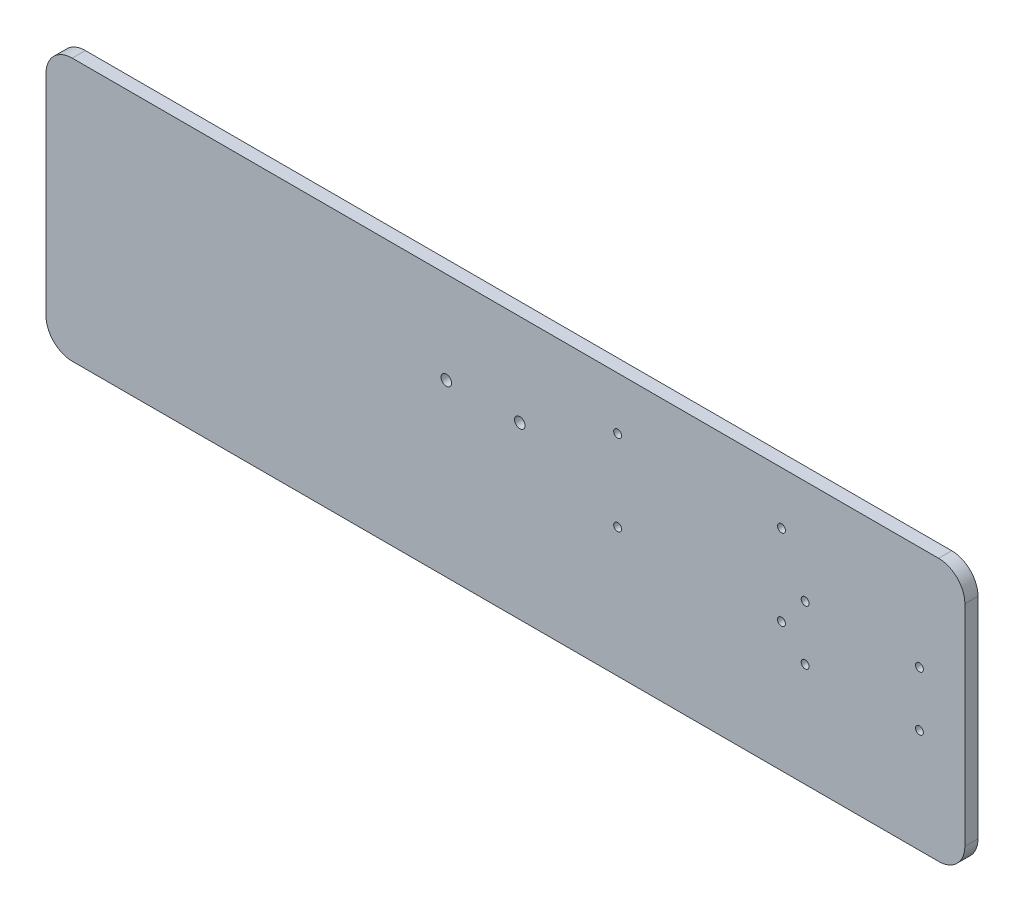
from build123d import *

# Parameters (mm, degrees)
BOSS_EXTRUDE1_DEPTH = 5
CUT_EXTRUDE1_REACH  = 7
SKETCH2_R           = 2
SKETCH2_R_2         = 1.5


with BuildPart() as part:
    # Sketch1 → Boss-Extrude1 (new body)
    with BuildSketch(Plane.XY):
        with BuildLine():
            Line((-165, -50), (165, -50))
            ThreePointArc((165, -50), (172.071067812, -47.071067812), (175, -40))
            Line((175, -40), (175, 40))
            ThreePointArc((175, 40), (172.071067812, 47.071067812), (165, 50))
            Line((165, 50), (-165, 50))
            ThreePointArc((-165, 50), (-172.071067812, 47.071067812), (-175, 40))
            Line((-175, 40), (-175, -40))
            ThreePointArc((-175, -40), (-172.071067812, -47.071067812), (-165, -50))
        make_face()
    extrude(amount=BOSS_EXTRUDE1_DEPTH)

    # Sketch2 → Cut-Extrude1 (cut, up to next)
    with BuildSketch(Plane(origin=(0, 0, 0), x_dir=(-1, 0, 0), z_dir=(0, 0, -1)), mode=Mode.PRIVATE) as cut_extrude1_sk1:
        with Locations((-5.457089812, 15)):
            Circle(SKETCH2_R)
    cut_extrude1_tool1 = extrude(cut_extrude1_sk1.sketch, amount=-CUT_EXTRUDE1_REACH, mode=Mode.PRIVATE) & part.part
    add(cut_extrude1_tool1.solids().sort_by_distance((5.45709, 15, 0))[0], mode=Mode.SUBTRACT)
    # Sketch2 → Cut-Extrude1 (cut, up to next)
    with BuildSketch(Plane(origin=(0, 0, 0), x_dir=(-1, 0, 0), z_dir=(0, 0, -1)), mode=Mode.PRIVATE) as cut_extrude1_sk2:
        with Locations((22.528132313, 15)):
            Circle(SKETCH2_R)
    cut_extrude1_tool2 = extrude(cut_extrude1_sk2.sketch, amount=-CUT_EXTRUDE1_REACH, mode=Mode.PRIVATE) & part.part
    add(cut_extrude1_tool2.solids().sort_by_distance((-22.528132, 15, 0))[0], mode=Mode.SUBTRACT)
    # Sketch2 → Cut-Extrude1 (cut, up to next)
    with BuildSketch(Plane(origin=(0, 0, 0), x_dir=(-1, 0, 0), z_dir=(0, 0, -1)), mode=Mode.PRIVATE) as cut_extrude1_sk3:
        with Locations((-105.153812798, 30)):
            Circle(SKETCH2_R_2)
    cut_extrude1_tool3 = extrude(cut_extrude1_sk3.sketch, amount=-CUT_EXTRUDE1_REACH, mode=Mode.PRIVATE) & part.part
    add(cut_extrude1_tool3.solids().sort_by_distance((105.153813, 30, 0))[0], mode=Mode.SUBTRACT)
    # Sketch2 → Cut-Extrude1 (cut, up to next)
    with BuildSketch(Plane(origin=(0, 0, 0), x_dir=(-1, 0, 0), z_dir=(0, 0, -1)), mode=Mode.PRIVATE) as cut_extrude1_sk4:
        with Locations((-42.738382893, 30)):
            Circle(SKETCH2_R_2)
    cut_extrude1_tool4 = extrude(cut_extrude1_sk4.sketch, amount=-CUT_EXTRUDE1_REACH, mode=Mode.PRIVATE) & part.part
    add(cut_extrude1_tool4.solids().sort_by_distance((42.738383, 30, 0))[0], mode=Mode.SUBTRACT)
    # Sketch2 → Cut-Extrude1 (cut, up to next)
    with BuildSketch(Plane(origin=(0, 0, 0), x_dir=(-1, 0, 0), z_dir=(0, 0, -1)), mode=Mode.PRIVATE) as cut_extrude1_sk5:
        with Locations((-42.738382893, -0.814499844)):
            Circle(SKETCH2_R_2)
    cut_extrude1_tool5 = extrude(cut_extrude1_sk5.sketch, amount=-CUT_EXTRUDE1_REACH, mode=Mode.PRIVATE) & part.part
    add(cut_extrude1_tool5.solids().sort_by_distance((42.738383, -0.8145, 0))[0], mode=Mode.SUBTRACT)
    # Sketch2 → Cut-Extrude1 (cut, up to next)
    with BuildSketch(Plane(origin=(0, 0, 0), x_dir=(-1, 0, 0), z_dir=(0, 0, -1)), mode=Mode.PRIVATE) as cut_extrude1_sk6:
        with Locations((-105.153812798, -0.814499844)):
            Circle(SKETCH2_R_2)
    cut_extrude1_tool6 = extrude(cut_extrude1_sk6.sketch, amount=-CUT_EXTRUDE1_REACH, mode=Mode.PRIVATE) & part.part
    add(cut_extrude1_tool6.solids().sort_by_distance((105.153813, -0.8145, 0))[0], mode=Mode.SUBTRACT)
    # Sketch2 → Cut-Extrude1 (cut, up to next)
    with BuildSketch(Plane(origin=(0, 0, 0), x_dir=(-1, 0, 0), z_dir=(0, 0, -1)), mode=Mode.PRIVATE) as cut_extrude1_sk7:
        with Locations((-114.15, -10.395)):
            Circle(SKETCH2_R_2)
    cut_extrude1_tool7 = extrude(cut_extrude1_sk7.sketch, amount=-CUT_EXTRUDE1_REACH, mode=Mode.PRIVATE) & part.part
    add(cut_extrude1_tool7.solids().sort_by_distance((114.15, -10.395, 0))[0], mode=Mode.SUBTRACT)
    # Sketch2 → Cut-Extrude1 (cut, up to next)
    with BuildSketch(Plane(origin=(0, 0, 0), x_dir=(-1, 0, 0), z_dir=(0, 0, -1)), mode=Mode.PRIVATE) as cut_extrude1_sk8:
        with Locations((-114.15, 10.395)):
            Circle(SKETCH2_R_2)
    cut_extrude1_tool8 = extrude(cut_extrude1_sk8.sketch, amount=-CUT_EXTRUDE1_REACH, mode=Mode.PRIVATE) & part.part
    add(cut_extrude1_tool8.solids().sort_by_distance((114.15, 10.395, 0))[0], mode=Mode.SUBTRACT)
    # Sketch2 → Cut-Extrude1 (cut, up to next)
    with BuildSketch(Plane(origin=(0, 0, 0), x_dir=(-1, 0, 0), z_dir=(0, 0, -1)), mode=Mode.PRIVATE) as cut_extrude1_sk9:
        with Locations((-157.7, -10.395)):
            Circle(SKETCH2_R_2)
    cut_extrude1_tool9 = extrude(cut_extrude1_sk9.sketch, amount=-CUT_EXTRUDE1_REACH, mode=Mode.PRIVATE) & part.part
    add(cut_extrude1_tool9.solids().sort_by_distance((157.7, -10.395, 0))[0], mode=Mode.SUBTRACT)
    # Sketch2 → Cut-Extrude1 (cut, up to next)
    with BuildSketch(Plane(origin=(0, 0, 0), x_dir=(-1, 0, 0), z_dir=(0, 0, -1)), mode=Mode.PRIVATE) as cut_extrude1_sk10:
        with Locations((-157.7, 10.395)):
            Circle(SKETCH2_R_2)
    cut_extrude1_tool10 = extrude(cut_extrude1_sk10.sketch, amount=-CUT_EXTRUDE1_REACH, mode=Mode.PRIVATE) & part.part
    add(cut_extrude1_tool10.solids().sort_by_distance((157.7, 10.395, 0))[0], mode=Mode.SUBTRACT)


solid = part.part
